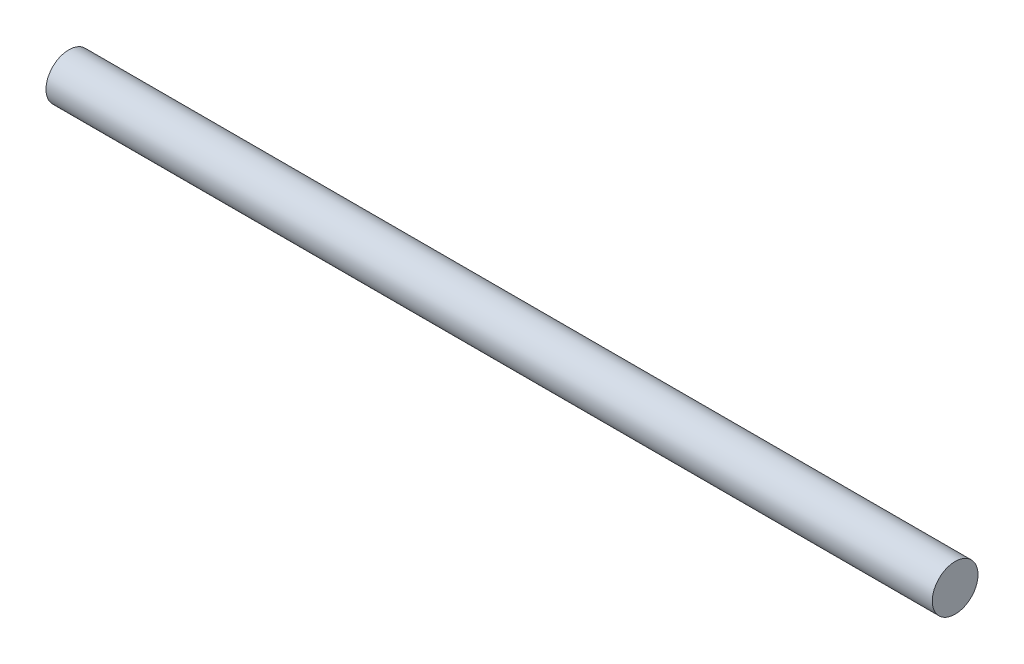
from build123d import *

# Parameters (mm, degrees)
SKETCH1_R           = 2.032
BOSS_EXTRUDE1_DEPTH = 78.74


with BuildPart() as part:
    # Sketch1 → Boss-Extrude1 (new body)
    with BuildSketch(Plane.ZY.offset(4.429149881)):
        with Locations((137.862132194, 119.089042557)):
            Circle(SKETCH1_R)
    extrude(amount=-BOSS_EXTRUDE1_DEPTH)


solid = part.part
